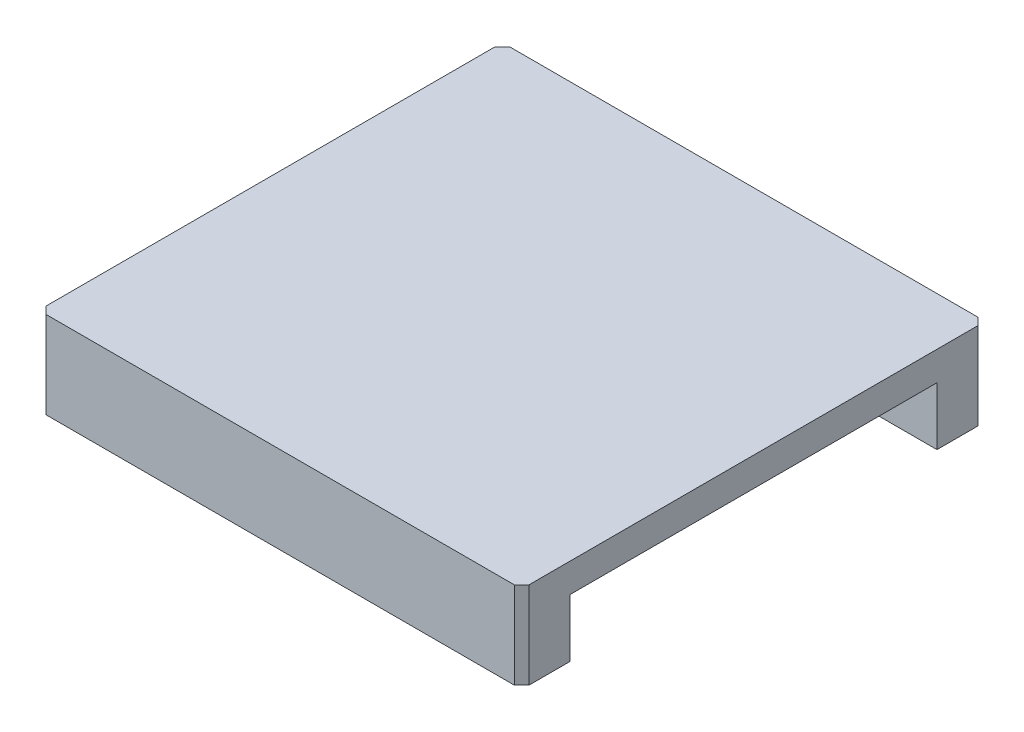
from build123d import *

# Parameters (mm, degrees)
ESTRUSIONE_ESTRUSIONE9_DEPTH = 50
SMUSSO1_SIZE                 = 0.75


with BuildPart() as part:
    # Schizzo16 → Estrusione-Estrusione9 (new body)
    with BuildSketch(Plane(origin=(0, 0, 0), x_dir=(0, 0, -1), z_dir=(1, 0, 0))):
        Polygon((0, 0), (5, 0), (5, 6), (43, 6), (43, 0), (48, 0), (48, 9), (0, 9), align=None)
    extrude(amount=ESTRUSIONE_ESTRUSIONE9_DEPTH)

    # Smusso1
    smusso1_edges = [part.edges().sort_by_distance(p)[0] for p in [
        (0, 4.5, 0),
        (50, 4.5, -48),
        (50, 4.5, 0),
        (0, 4.5, -48),
    ]]
    chamfer(smusso1_edges, length=SMUSSO1_SIZE)


solid = part.part
